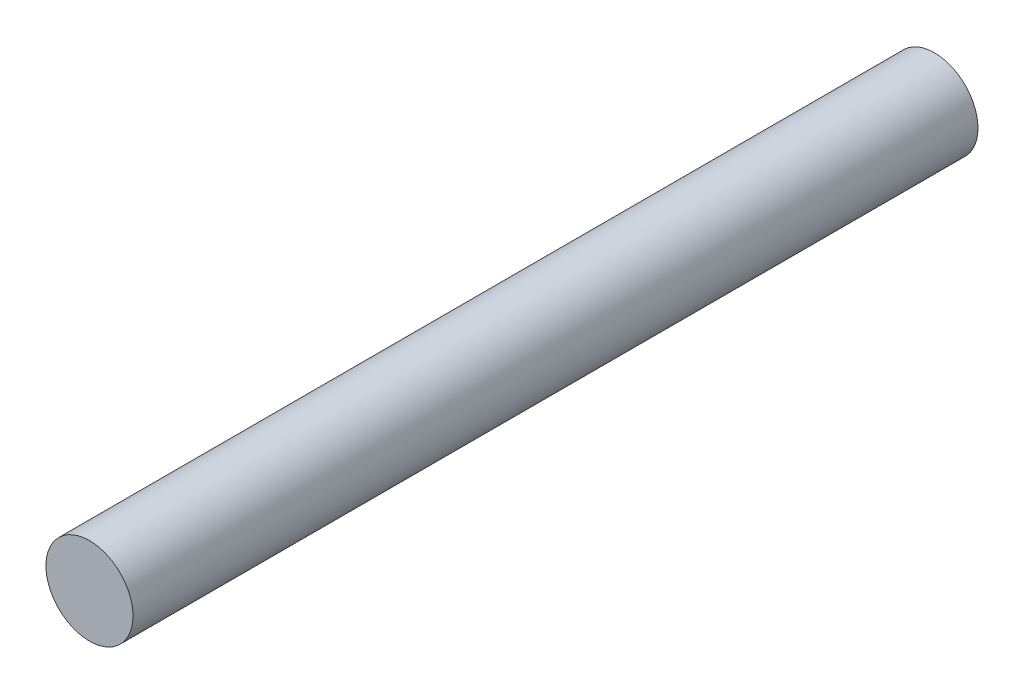
from build123d import *

# Parameters (mm, degrees)
SKETCH1_R           = 3.175
BOSS_EXTRUDE1_DEPTH = 61.595


with BuildPart() as part:
    # Sketch1 → Boss-Extrude1 (new body)
    with BuildSketch(Plane.XY):
        Circle(SKETCH1_R)
    extrude(amount=BOSS_EXTRUDE1_DEPTH)


solid = part.part
